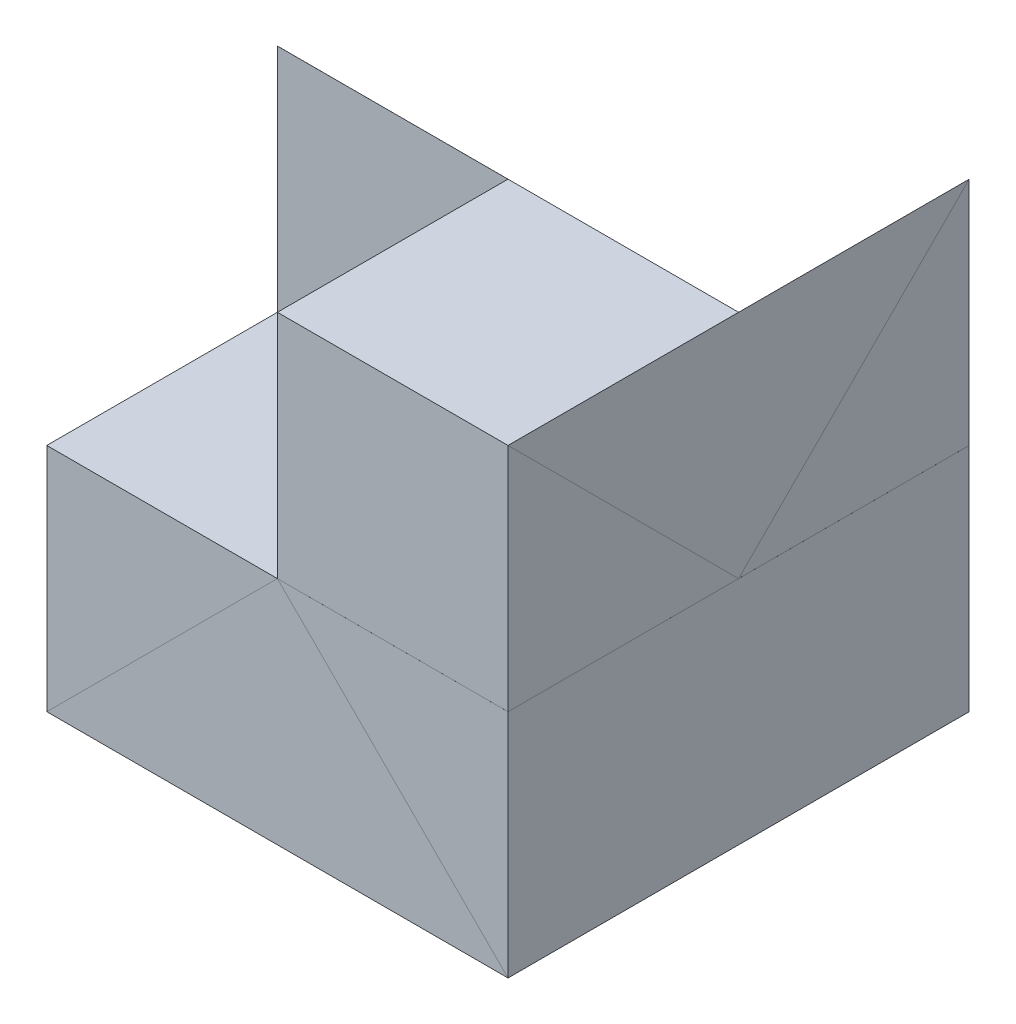
from build123d import *

# Parameters (mm, degrees)
SKETCH1_W           = 40
SKETCH1_H           = 40
BOSS_EXTRUDE1_DEPTH = 40
SKETCH2_W           = 20
SKETCH2_H           = 20
CUT_EXTRUDE1_DEPTH  = 20
SKETCH3_W           = 20
SKETCH3_H           = 20
CUT_EXTRUDE2_DEPTH  = 10
CUT_EXTRUDE7_DEPTH  = 10
SKETCH8_W           = 20
SKETCH8_H           = 20
BOSS_EXTRUDE2_DEPTH = 10
CUT_EXTRUDE8_DEPTH  = 10
SKETCH10_W          = 20
SKETCH10_H          = 20
CUT_EXTRUDE9_DEPTH  = 5
CUT_EXTRUDE13_DEPTH = 10
SKETCH13_W          = 20
SKETCH13_H          = 20
CUT_EXTRUDE15_DEPTH = 20
CUT_EXTRUDE16_DEPTH = 0.001
CUT_EXTRUDE21_DEPTH = 0.001
SKETCH17_W          = 20
SKETCH17_H          = 20
BOSS_EXTRUDE5_DEPTH = 14.999
CUT_EXTRUDE23_DEPTH = 0.0001
BOSS_EXTRUDE6_DEPTH = 0.0001
SKETCH21_W          = 20
SKETCH21_H          = 20
CUT_EXTRUDE25_DEPTH = 9.998
BOSS_EXTRUDE7_DEPTH = 9.998
CUT_EXTRUDE26_DEPTH = 0.0001


with BuildPart() as part:
    # Sketch1 → Boss-Extrude1 (new body)
    with BuildSketch(Plane.XY):
        with Locations((20, 20)):
            Rectangle(SKETCH1_W, SKETCH1_H)
    extrude(amount=BOSS_EXTRUDE1_DEPTH)

    # Sketch2 → Cut-Extrude1 (cut)
    with BuildSketch(Plane.XY.offset(40)):
        with Locations((30, 30)):
            Rectangle(SKETCH2_W, SKETCH2_H)
    extrude(amount=-CUT_EXTRUDE1_DEPTH, mode=Mode.SUBTRACT)

    # Sketch3 → Cut-Extrude2 (cut)
    with BuildSketch(Plane.XY.offset(40)):
        with Locations((10, 30)):
            Rectangle(SKETCH3_W, SKETCH3_H)
    extrude(amount=-CUT_EXTRUDE2_DEPTH, mode=Mode.SUBTRACT)

    # Sketch7 → Cut-Extrude7 (cut)
    with BuildSketch(Plane(origin=(0, 0, 0), x_dir=(-1, 0, 0), z_dir=(0, 0, -1))):
        Polygon((-40, 40), (-20, 20), (0, 40), align=None)
    extrude(amount=-CUT_EXTRUDE7_DEPTH, mode=Mode.SUBTRACT)

    # Sketch8 → Boss-Extrude2 (add)
    with BuildSketch(Plane.XY.offset(20)):
        with Locations((30, 30)):
            Rectangle(SKETCH8_W, SKETCH8_H)
    extrude(amount=BOSS_EXTRUDE2_DEPTH)

    # Sketch9 → Cut-Extrude8 (cut)
    with BuildSketch(Plane(origin=(0, 0, 10), x_dir=(-1, 0, 0), z_dir=(0, 0, -1))):
        Polygon((-40, 40), (-20, 20), (0, 40), align=None)
    extrude(amount=-CUT_EXTRUDE8_DEPTH, mode=Mode.SUBTRACT)

    # Sketch10 → Cut-Extrude9 (cut)
    with BuildSketch(Plane.XY.offset(30)):
        with Locations((30, 30)):
            Rectangle(SKETCH10_W, SKETCH10_H)
    extrude(amount=-CUT_EXTRUDE9_DEPTH, mode=Mode.SUBTRACT)

    # Sketch12 → Cut-Extrude13 (cut)
    with BuildSketch(Plane.XY.offset(40)):
        Polygon((0, 0), (19.999, 19.999), (40, 0), align=None)
    extrude(amount=-CUT_EXTRUDE13_DEPTH, mode=Mode.SUBTRACT)

    # Sketch13 → Cut-Extrude15 (cut)
    with BuildSketch(Plane.ZY):
        with Locations((10, 30)):
            Rectangle(SKETCH13_W, SKETCH13_H)
    extrude(amount=-CUT_EXTRUDE15_DEPTH, mode=Mode.SUBTRACT)

    # Sketch14 → Cut-Extrude16 (cut)
    with BuildSketch(Plane(origin=(0, 0, 20), x_dir=(-1, 0, 0), z_dir=(0, 0, -1))):
        Polygon((-20, 20), (0, 40), (0, 20), align=None)
    extrude(amount=-CUT_EXTRUDE16_DEPTH, mode=Mode.SUBTRACT)

    # Sketch16 → Cut-Extrude21 (cut)
    with BuildSketch(Plane(origin=(40, 0, 0), x_dir=(0, 0, -1), z_dir=(1, 0, 0))):
        Polygon((0, 40), (-20, 20), (0, 20), align=None)
    extrude(amount=-CUT_EXTRUDE21_DEPTH, mode=Mode.SUBTRACT)

    # Sketch17 → Boss-Extrude5 (add)
    with BuildSketch(Plane.XY.offset(25)):
        with Locations((30, 30)):
            Rectangle(SKETCH17_W, SKETCH17_H)
    extrude(amount=BOSS_EXTRUDE5_DEPTH)

    # Sketch18 → Cut-Extrude23 (cut)
    with BuildSketch(Plane(origin=(40, 0, 0), x_dir=(0, 0, -1), z_dir=(1, 0, 0))):
        Polygon((-40, 20), (-20.001, 20), (-39.999, 40), align=None)
    extrude(amount=-CUT_EXTRUDE23_DEPTH, mode=Mode.SUBTRACT)

    # Sketch20 → Boss-Extrude6 (add)
    with BuildSketch(Plane(origin=(0, 0, 20.001), x_dir=(-1, 0, 0), z_dir=(0, 0, -1))):
        Polygon((-20, 20), (0, 20), (0, 40), align=None)
    extrude(amount=BOSS_EXTRUDE6_DEPTH)

    # Sketch21 → Cut-Extrude25 (cut)
    with BuildSketch(Plane.XY.offset(30)):
        with Locations((10, 30)):
            Rectangle(SKETCH21_W, SKETCH21_H)
    extrude(amount=-CUT_EXTRUDE25_DEPTH, mode=Mode.SUBTRACT)

    # Sketch22 → Boss-Extrude7 (add)
    with BuildSketch(Plane.XY.offset(30)):
        Polygon((0, 0), (20, 20), (40, 0), align=None)
    extrude(amount=BOSS_EXTRUDE7_DEPTH)

    # Sketch23 → Cut-Extrude26 (cut)
    with BuildSketch(Plane.ZY):
        Polygon((0, 0), (20, 19.999), (40, 0), align=None)
    extrude(amount=-CUT_EXTRUDE26_DEPTH, mode=Mode.SUBTRACT)


solid = part.part
